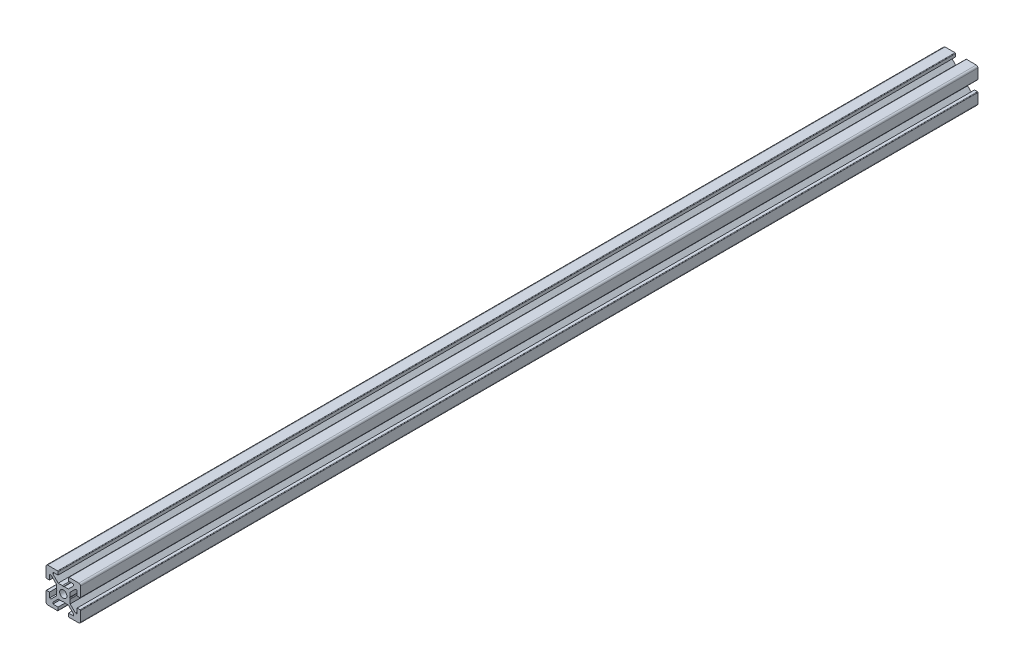
from build123d import *

# Parameters (mm, degrees)
BOSS_EXTRUDE1_DEPTH = 519.5
SKETCH2_W           = 519.5
SKETCH2_H           = 2.1
SKETCH4_R           = 2.6
CUT_EXTRUDE2_DEPTH  = 20


with BuildPart() as part:
    # Sketch1 → Boss-Extrude1 (new body)
    with BuildSketch(Plane.XY):
        with BuildLine():
            Line((-10, 9), (-10, 3.29999995))
            ThreePointArc((-10, 3.29999995), (-9.912132049, 3.087867916), (-9.7, 3))
            Line((-9.7, 3), (-8, 3))
            Line((-8, 3), (-8, 6))
            Line((-8, 6), (-7.060677, 6))
            Line((-7.060677, 6), (-4, 2.93932965))
            Line((-4, 2.93932965), (-4, 0.519615242))
            Line((-4, 0.519615242), (-3.699996283, -6.437e-06))
            Line((-3.699996283, -6.437e-06), (-4, -0.519628117))
            Line((-4, -0.519628117), (-4, -2.93933725))
            Line((-4, -2.93933725), (-7.0606695, -6))
            Line((-7.0606695, -6), (-8, -6))
            Line((-8, -6), (-8, -3))
            Line((-8, -3), (-9.7, -3))
            ThreePointArc((-9.7, -3), (-9.912132049, -3.087867916), (-10, -3.29999995))
            Line((-10, -3.29999995), (-10, -9))
            ThreePointArc((-10, -9), (-9.707106781, -9.707106781), (-9, -10))
            Line((-9, -10), (-3.29999995, -10))
            ThreePointArc((-3.29999995, -10), (-3.087867916, -9.912132049), (-3, -9.7))
            Line((-3, -9.7), (-3, -8))
            Line((-3, -8), (-6, -8))
            Line((-6, -8), (-6, -7.0606515))
            Line((-6, -7.0606515), (-2.9393489, -4))
            Line((-2.9393489, -4), (-0.519615242, -4))
            Line((-0.519615242, -4), (6.437e-06, -3.699996283))
            Line((6.437e-06, -3.699996283), (0.519628117, -4))
            Line((0.519628117, -4), (2.9393227, -4))
            Line((2.9393227, -4), (6, -7.060677))
            Line((6, -7.060677), (6, -8))
            Line((6, -8), (3, -8))
            Line((3, -8), (3, -9.7))
            ThreePointArc((3, -9.7), (3.087867916, -9.912132049), (3.29999995, -10))
            Line((3.29999995, -10), (9, -10))
            ThreePointArc((9, -10), (9.707106781, -9.707106781), (10, -9))
            Line((10, -9), (10, -3.29999995))
            ThreePointArc((10, -3.29999995), (9.912132049, -3.087867916), (9.7, -3))
            Line((9.7, -3), (8, -3))
            Line((8, -3), (8, -6))
            Line((8, -6), (7.0606435, -6))
            Line((7.0606435, -6), (4, -2.9393482))
            Line((4, -2.9393482), (4, -0.519615242))
            Line((4, -0.519615242), (3.699996283, 6.437e-06))
            Line((3.699996283, 6.437e-06), (4, 0.519628117))
            Line((4, 0.519628117), (4, 2.9393401))
            Line((4, 2.9393401), (7.060651, 6))
            Line((7.060651, 6), (8, 6))
            Line((8, 6), (8, 3))
            Line((8, 3), (9.7, 3))
            ThreePointArc((9.7, 3), (9.912132049, 3.087867916), (10, 3.29999995))
            Line((10, 3.29999995), (10, 9))
            ThreePointArc((10, 9), (9.707106781, 9.707106781), (9, 10))
            Line((9, 10), (3.29999995, 10))
            ThreePointArc((3.29999995, 10), (3.087867916, 9.912132049), (3, 9.7))
            Line((3, 9.7), (3, 8))
            Line((3, 8), (6, 8))
            Line((6, 8), (6, 7.060669))
            Line((6, 7.060669), (2.9393308, 4))
            Line((2.9393308, 4), (0.519615242, 4))
            Line((0.519615242, 4), (-6.437e-06, 3.699996283))
            Line((-6.437e-06, 3.699996283), (-0.519628117, 4))
            Line((-0.519628117, 4), (-2.93935655, 4))
            Line((-2.93935655, 4), (-6, 7.0606435))
            Line((-6, 7.0606435), (-6, 8))
            Line((-6, 8), (-3, 8))
            Line((-3, 8), (-3, 9.7))
            ThreePointArc((-3, 9.7), (-3.087867966, 9.912132034), (-3.3, 10))
            Line((-3.3, 10), (-9, 10))
            ThreePointArc((-9, 10), (-9.707106781, 9.707106781), (-10, 9))
        make_face()
    extrude(amount=-BOSS_EXTRUDE1_DEPTH)

    # Sketch2 → Cut-Revolve1 (revolve, cut)
    with BuildSketch(Plane(origin=(0, 0, 0), x_dir=(0, 0, -1), z_dir=(1, 0, 0))):
        with Locations((259.75, 1.05)):
            Rectangle(SKETCH2_W, SKETCH2_H)
    revolve(axis=Axis((0, 0, -519.5), (0, 0, 1)), mode=Mode.SUBTRACT)

    # Sketch4 → Cut-Extrude2 (cut)
    with BuildSketch(Plane(origin=(0, 10, 0), x_dir=(0, 0, -1), z_dir=(0, -1, 0))):
        with Locations((459.75, 0)):
            Circle(SKETCH4_R)
        with Locations((59.75, 0)):
            Circle(SKETCH4_R)
    extrude(amount=CUT_EXTRUDE2_DEPTH, mode=Mode.SUBTRACT)


solid = part.part
